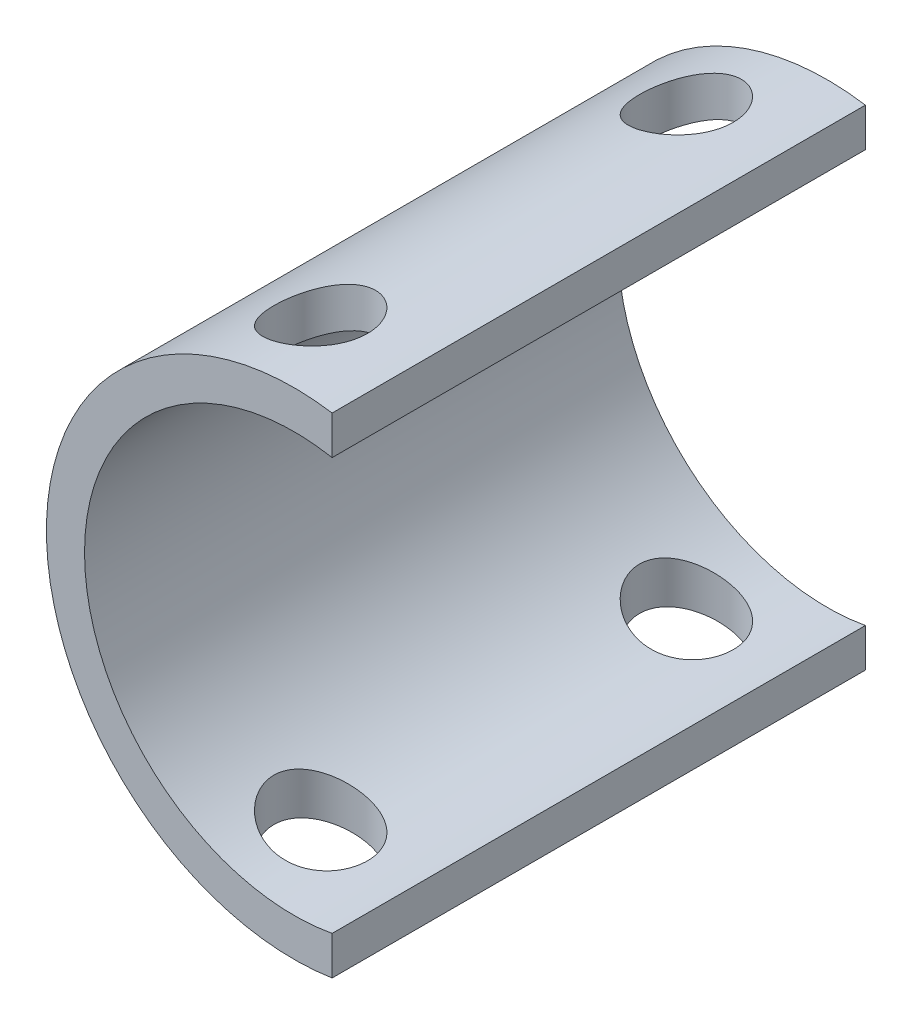
from build123d import *

# Parameters (mm, degrees)
ESQUISSE2_R                  = 65
ESQUISSE1_R                  = 65
ESQUISSE4_W                  = 168.541891076
ESQUISSE4_H                  = 143.597897644
ENL_V_MAT_EXTRU_2_DEPTH      = 56.0000001
COQUE2_T                     = -10
ESQUISSE5_R                  = 55
ENL_V_MAT_EXTRU_3_DEPTH      = 141
ESQUISSE6_R                  = 12.294398433
ENL_V_MAT_EXTRU_4_DEPTH      = 66
ENL_V_MAT_EXTRU_4_DEPTH_BACK = 66


with BuildPart() as part:
    # Esquisse2 → Lissage2 section 0
    with BuildSketch(Plane(origin=(0, 0, 140), x_dir=(-1, 0, 0), z_dir=(0, 0, -1))):
        Circle(ESQUISSE2_R)
    # Esquisse1 → Lissage2 section 1
    with BuildSketch(Plane.XY):
        Circle(ESQUISSE1_R)
    loft()

    # Esquisse4 → Enlèv. mat.-Extru.2 (cut, through all)
    with BuildSketch(Plane(origin=(10, 0, 0), x_dir=(0, 0, -1), z_dir=(1, 0, 0))):
        with Locations((-79.475842773, 1.247725941)):
            Rectangle(ESQUISSE4_W, ESQUISSE4_H)
    extrude(amount=ENL_V_MAT_EXTRU_2_DEPTH, mode=Mode.SUBTRACT)

    # Coque2
    coque2_openings = [part.faces().sort_by_distance(p)[0] for p in [
        (10, 7.25e-07, 70),
    ]]
    offset(amount=COQUE2_T, openings=coque2_openings)

    # Esquisse5 → Enlèv. mat.-Extru.3 (cut, through all)
    with BuildSketch(Plane.XY):
        Circle(ESQUISSE5_R)
    extrude(amount=ENL_V_MAT_EXTRU_3_DEPTH, mode=Mode.SUBTRACT)

    # Esquisse6 → Enlèv. mat.-Extru.4 (cut, two sides)
    with BuildSketch(Plane(origin=(0, 0, 0), x_dir=(1, 0, 0), z_dir=(0, 1, 0))) as enl_v_mat_extru_4_sk:
        with Locations((-15, -22)):
            Circle(ESQUISSE6_R)
        with Locations((-15, -118)):
            Circle(ESQUISSE6_R)
    extrude(amount=ENL_V_MAT_EXTRU_4_DEPTH, mode=Mode.SUBTRACT)
    extrude(enl_v_mat_extru_4_sk.sketch, amount=-ENL_V_MAT_EXTRU_4_DEPTH_BACK, mode=Mode.SUBTRACT)


solid = part.part
